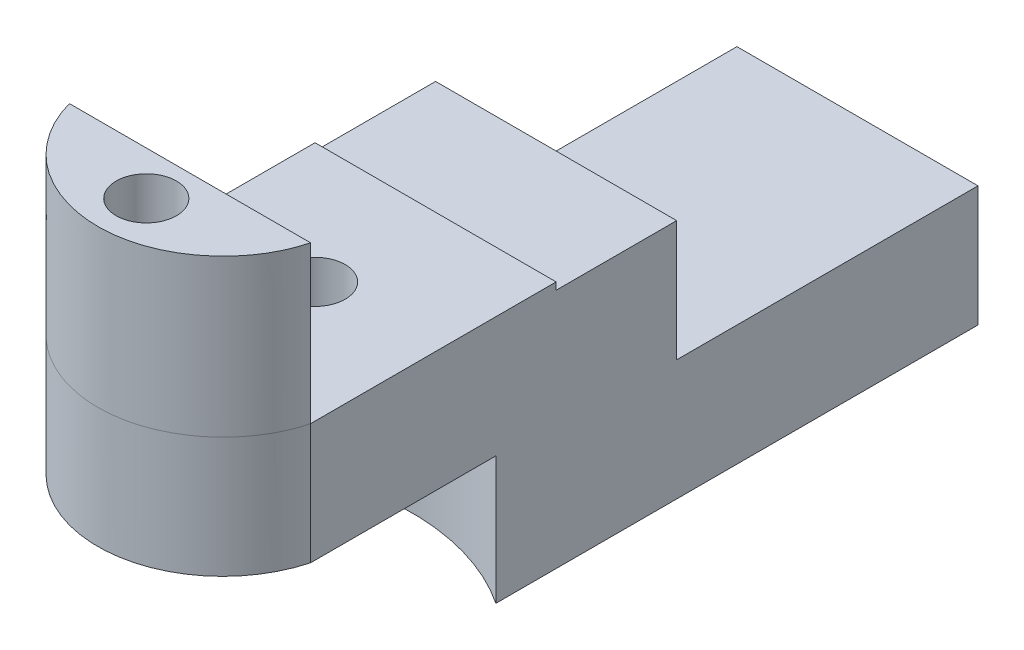
from build123d import *

# Parameters (mm, degrees)
SKETCH1_R               = 0.635
BOSS_EXTRUDE1_DEPTH     = 2.54
CUT_EXTRUDE1_DEPTH      = 2.54
CUT_EXTRUDE1_DEPTH_BACK = 5.08
SKETCH4_R               = 0.635
BOSS_EXTRUDE2_DEPTH     = 3.302
SKETCH5_W               = 5.08
SKETCH5_H               = 2.54
BOSS_EXTRUDE3_DEPTH     = 1.27
BOSS_EXTRUDE4_DEPTH     = 2.691815502
SKETCH7_W               = 5.08
SKETCH7_H               = 5.08
BOSS_EXTRUDE6_DEPTH     = 2.54
SKETCH8_W               = 5.08
SKETCH8_H               = 2.54
BOSS_EXTRUDE7_DEPTH     = 6.35


with BuildPart() as part:
    # Sketch1 → Boss-Extrude1 (new body)
    with BuildSketch(Plane(origin=(0, 0, 0), x_dir=(1, 0, 0), z_dir=(0, 1, 0))):
        with BuildLine():
            Line((1.27, -3.81), (-1.27, -3.81))
            ThreePointArc((-1.27, -3.81), (-2.168025612, -3.438025612), (-2.54, -2.54))
            Line((-2.54, -2.54), (-2.54, 3.81))
            Line((-2.54, 3.81), (2.54, 3.81))
            Line((2.54, 3.81), (2.54, -2.54))
            ThreePointArc((2.54, -2.54), (2.168025612, -3.438025612), (1.27, -3.81))
        make_face()
        with Locations(Location((0, 2.54, 0), (0, 0, 270))):
            Circle(SKETCH1_R, mode=Mode.SUBTRACT)
        with Locations(Location((0, -1.016, 0), (0, 0, 270))):
            Circle(SKETCH1_R, mode=Mode.SUBTRACT)
    extrude(amount=BOSS_EXTRUDE1_DEPTH)

    # Sketch3 → Cut-Extrude1 (cut, two sides)
    with BuildSketch(Plane(origin=(0, 2.54, 0), x_dir=(1, 0, 0), z_dir=(0, 1, 0))) as cut_extrude1_sk:
        with BuildLine():
            Line((-2.54, -0.095828679), (-2.694274157, -4.645461949))
            Line((-2.694274157, -4.645461949), (2.54, -5.194052166))
            Line((2.54, -5.194052166), (2.54, -0.095828679))
            ThreePointArc((2.54, -0.095828679), (0, -2.039478025), (-2.54, -0.095828679))
        make_face()
    extrude(amount=CUT_EXTRUDE1_DEPTH, mode=Mode.SUBTRACT)
    extrude(cut_extrude1_sk.sketch, amount=-CUT_EXTRUDE1_DEPTH_BACK, mode=Mode.SUBTRACT)

    # Sketch4 → Boss-Extrude2 (add)
    with BuildSketch(Plane(origin=(0, 2.54, 0), x_dir=(1, 0, 0), z_dir=(0, 1, 0))):
        with BuildLine():
            Line((-2.54, -0.095828679), (2.54, -0.095828679))
            add(Edge.make_bspline(
                [(-2.54, -0.095828679), (-2.376202283, -0.715149279), (-1.653412381, -1.701782701), (-0.15770648, -2.137299213), (1.479197277, -1.818139784), (2.343023282, -0.881746046), (2.54, -0.095828679)],
                knots=[0, 0, 0, 0, 0.281857039, 0.499578662, 0.64728967, 1, 1, 1, 1], degree=3))
        make_face()
        with Locations(Location((0, -1.016, 0), (0, 0, 270))):
            Circle(SKETCH4_R, mode=Mode.SUBTRACT)
    extrude(amount=BOSS_EXTRUDE2_DEPTH)

    # Sketch5 → Boss-Extrude3 (add)
    with BuildSketch(Plane(origin=(0, 0, -3.81), x_dir=(-1, 0, 0), z_dir=(0, 0, -1))):
        with Locations((0, 1.27)):
            Rectangle(SKETCH5_W, SKETCH5_H)
    extrude(amount=BOSS_EXTRUDE3_DEPTH)

    # Sketch6 → Boss-Extrude4 (add)
    with BuildSketch(Plane(origin=(0, 0, 0), x_dir=(-1, 0, 0), z_dir=(0, -1, 0))):
        with BuildLine():
            Line((-2.54, 5.08), (-2.54, 3.81))
            ThreePointArc((-2.54, 3.81), (0, 4.57905012), (2.54, 3.81))
            Line((2.54, 3.81), (2.54, 5.08))
            Line((2.54, 5.08), (-2.54, 5.08))
        make_face()
    extrude(amount=BOSS_EXTRUDE4_DEPTH)

    # Sketch7 → Boss-Extrude6 (add)
    with BuildSketch(Plane(origin=(0, 0, -5.08), x_dir=(-1, 0, 0), z_dir=(0, 0, -1))):
        with Locations((0, -0.151815502)):
            Rectangle(SKETCH7_W, SKETCH7_H)
    extrude(amount=BOSS_EXTRUDE6_DEPTH)

    # Sketch8 → Boss-Extrude7 (add)
    with BuildSketch(Plane(origin=(0, 0, -7.62), x_dir=(-1, 0, 0), z_dir=(0, 0, -1))):
        with Locations((0, -1.421815502)):
            Rectangle(SKETCH8_W, SKETCH8_H)
    extrude(amount=BOSS_EXTRUDE7_DEPTH)


solid = part.part
